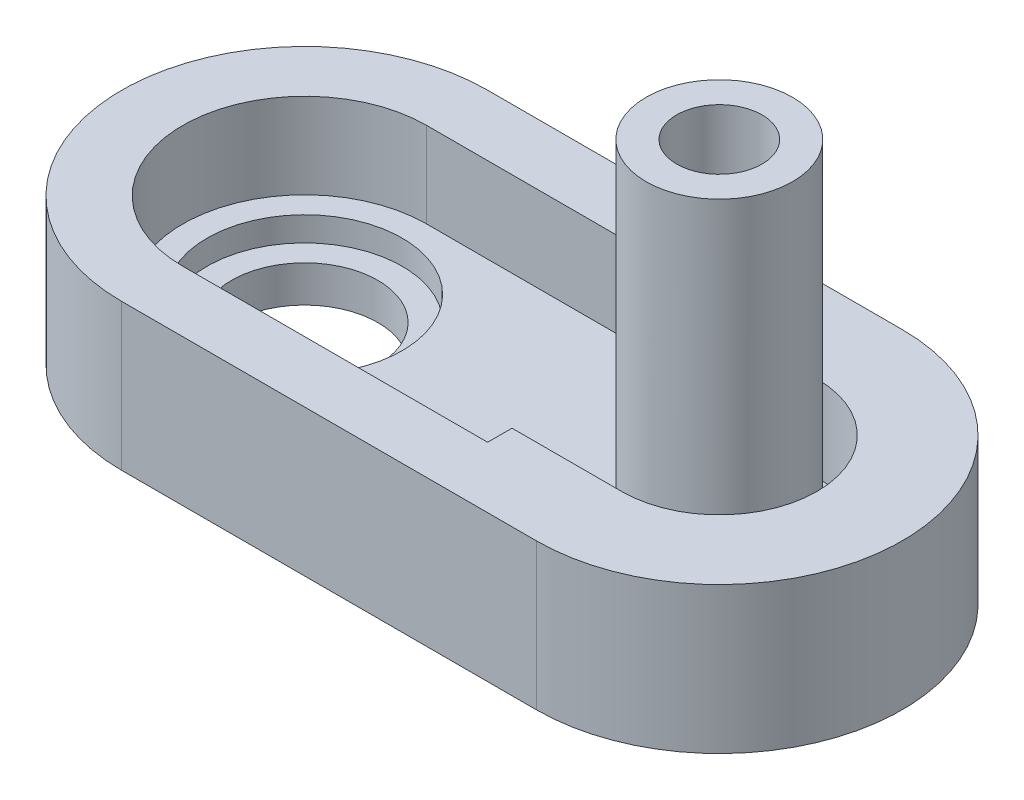
from build123d import *

# Parameters (mm, degrees)
BOSS_EXTRUDE1_DEPTH = 12
CUT_EXTRUDE1_DEPTH  = 7
SKETCH3_R           = 6
SKETCH3_R_2         = 3.5
BOSS_EXTRUDE2_DEPTH = 28
CUT_EXTRUDE2_START  = -28
SKETCH4_R           = 3.5
CUT_EXTRUDE2_DEPTH  = 28
SKETCH5_R           = 8
SKETCH5_R_2         = 6
CUT_EXTRUDE3_DEPTH  = 2
SKETCH5_3_R         = 6
CUT_EXTRUDE4_DEPTH  = 46.08880127


with BuildPart() as part:
    # Sketch1 → Boss-Extrude1 (new body)
    with BuildSketch(Plane(origin=(0, 0, 0), x_dir=(1, 0, 0), z_dir=(0, 1, 0))):
        with BuildLine():
            Line((-17, 15), (17, 15))
            ThreePointArc((17, 15), (32, 0), (17, -15))
            Line((17, -15), (-17, -15))
            ThreePointArc((-17, -15), (-32, 0), (-17, 15))
        make_face()
    extrude(amount=BOSS_EXTRUDE1_DEPTH)

    # Sketch2 → Cut-Extrude1 (cut)
    with BuildSketch(Plane(origin=(0, 12, 0), x_dir=(1, 0, 0), z_dir=(0, 1, 0))):
        with BuildLine():
            Line((8, 10), (-17, 10))
            ThreePointArc((-17, 10), (-27, 0), (-17, -10))
            Line((-17, -10), (8, -10))
            Line((8, -10), (8, -8))
            Line((8, -8), (17, -8))
            ThreePointArc((17, -8), (25, 0), (17, 8))
            Line((17, 8), (8, 8))
            Line((8, 8), (8, 10))
        make_face()
    extrude(amount=-CUT_EXTRUDE1_DEPTH, mode=Mode.SUBTRACT)

    # Sketch3 → Boss-Extrude2 (add)
    with BuildSketch(Plane(origin=(0, 5, 0), x_dir=(1, 0, 0), z_dir=(0, 1, 0))):
        with Locations((17, 0)):
            Circle(SKETCH3_R)
        with Locations((17, 0)):
            Circle(SKETCH3_R_2, mode=Mode.SUBTRACT)
    extrude(amount=BOSS_EXTRUDE2_DEPTH)

    # Sketch4 → Cut-Extrude2 (cut)
    with BuildSketch(Plane(origin=(0, 5, 0), x_dir=(1, 0, 0), z_dir=(0, 1, 0)).offset(CUT_EXTRUDE2_START)):
        with Locations((17, 0)):
            Circle(SKETCH4_R)
    extrude(amount=CUT_EXTRUDE2_DEPTH, mode=Mode.SUBTRACT)

    # Sketch5 → Cut-Extrude3 (cut)
    with BuildSketch(Plane(origin=(0, 5, 0), x_dir=(1, 0, 0), z_dir=(0, 1, 0))):
        with Locations((-17, 0)):
            Circle(SKETCH5_R)
        with Locations((-17, 0)):
            Circle(SKETCH5_R_2, mode=Mode.SUBTRACT)
    extrude(amount=-CUT_EXTRUDE3_DEPTH, mode=Mode.SUBTRACT)

    # Sketch5_3 → Cut-Extrude4 (cut, through all)
    with BuildSketch(Plane(origin=(0, 5, 0), x_dir=(1, 0, 0), z_dir=(0, 1, 0))):
        with Locations((-17, 0)):
            Circle(SKETCH5_3_R)
    extrude(amount=-CUT_EXTRUDE4_DEPTH, mode=Mode.SUBTRACT)


solid = part.part
